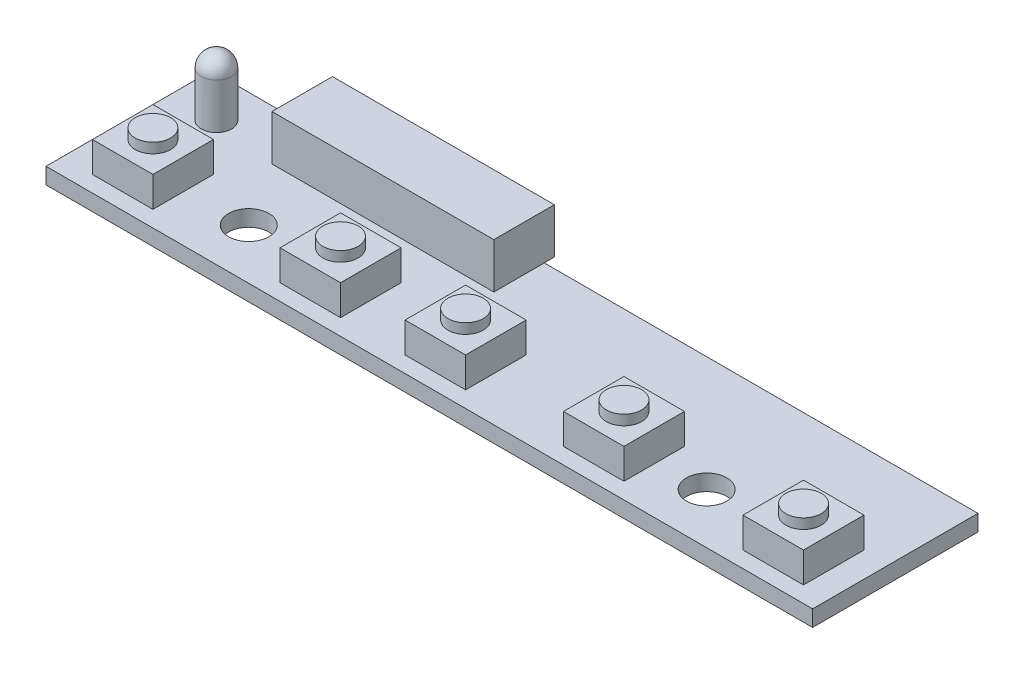
from build123d import *

# Parameters (mm, degrees)
SZKIC1_W                    = 76
SZKIC1_H                    = 16.4
SZKIC1_R                    = 2
DODANIE_WYCI_GNI_CIE1_DEPTH = 1.6
SZKIC2_W                    = 6
SZKIC2_H                    = 6
DODANIE_WYCI_GNI_CIE2_DEPTH = 3
SZKIC3_R                    = 1.75
DODANIE_WYCI_GNI_CIE3_DEPTH = 1
SZKIC4_R                    = 1.5
DODANIE_WYCI_GNI_CIE4_DEPTH = 6
ZAOKR_GLENIE1_R             = 1.5
SZKIC5_W                    = 22
SZKIC5_H                    = 6
DODANIE_WYCI_GNI_CIE5_DEPTH = 4.5


with BuildPart() as part:
    # Szkic1 → Dodanie-wyciągnięcie1 (new body)
    with BuildSketch(Plane(origin=(0, 0, 0), x_dir=(1, 0, 0), z_dir=(0, 1, 0))):
        Rectangle(SZKIC1_W, SZKIC1_H)
        with Locations((-22.9, -3.2)):
            Circle(SZKIC1_R, mode=Mode.SUBTRACT)
        with Locations((22.5, -3.2)):
            Circle(SZKIC1_R, mode=Mode.SUBTRACT)
    extrude(amount=DODANIE_WYCI_GNI_CIE1_DEPTH)

    # Szkic2 → Dodanie-wyciągnięcie2 (add)
    with BuildSketch(Plane(origin=(0, 1.6, 0), x_dir=(1, 0, 0), z_dir=(0, 1, 0))):
        with Locations((-32, -3.6)):
            Rectangle(SZKIC2_W, SZKIC2_H)
        with Locations((-13.4, -3.6)):
            Rectangle(SZKIC2_W, SZKIC2_H)
        with Locations((-1, -3.6)):
            Rectangle(SZKIC2_W, SZKIC2_H)
        with Locations((14.7, -3.6)):
            Rectangle(SZKIC2_W, SZKIC2_H)
        with Locations((32.5, -3.6)):
            Rectangle(SZKIC2_W, SZKIC2_H)
    extrude(amount=DODANIE_WYCI_GNI_CIE2_DEPTH)

    # Szkic3 → Dodanie-wyciągnięcie3 (add)
    with BuildSketch(Plane(origin=(0, 4.6, 0), x_dir=(1, 0, 0), z_dir=(0, 1, 0))):
        with Locations((-32, -3.6)):
            Circle(SZKIC3_R)
        with Locations((-13.4, -3.6)):
            Circle(SZKIC3_R)
        with Locations((-1, -3.6)):
            Circle(SZKIC3_R)
        with Locations((14.7, -3.6)):
            Circle(SZKIC3_R)
        with Locations((32.5, -3.6)):
            Circle(SZKIC3_R)
    extrude(amount=DODANIE_WYCI_GNI_CIE3_DEPTH)

    # Szkic4 → Dodanie-wyciągnięcie4 (add)
    with BuildSketch(Plane(origin=(0, 1.6, 0), x_dir=(1, 0, 0), z_dir=(0, 1, 0))):
        with Locations((-33.5, 4.2)):
            Circle(SZKIC4_R)
    extrude(amount=DODANIE_WYCI_GNI_CIE4_DEPTH)

    # Zaokrąglenie1
    zaokr_glenie1_edges = [part.edges().sort_by_distance(p)[0] for p in [
        (-35, 7.6, -4.2),
    ]]
    fillet(zaokr_glenie1_edges, radius=ZAOKR_GLENIE1_R)

    # Szkic5 → Dodanie-wyciągnięcie5 (add)
    with BuildSketch(Plane(origin=(0, 1.6, 0), x_dir=(1, 0, 0), z_dir=(0, 1, 0))):
        with Locations((-16, 6.2)):
            Rectangle(SZKIC5_W, SZKIC5_H)
    extrude(amount=DODANIE_WYCI_GNI_CIE5_DEPTH)


solid = part.part
